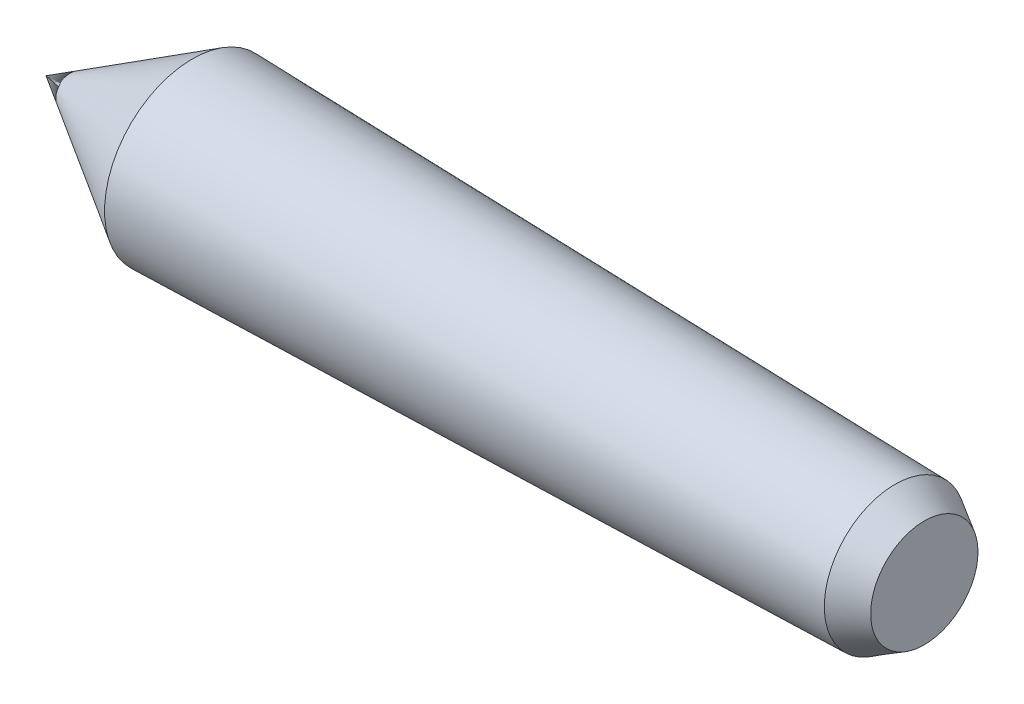
from build123d import *


with BuildPart() as part:
    # Sketch1 → Revolve1 (revolve)
    with BuildSketch(Plane.XY):
        Polygon((0, 0), (15, 9), (87, 7.25), (90, 5.5), (90, 0), align=None)
    revolve(axis=Axis((90, 0, 0), (-1, 0, 0)))


solid = part.part
